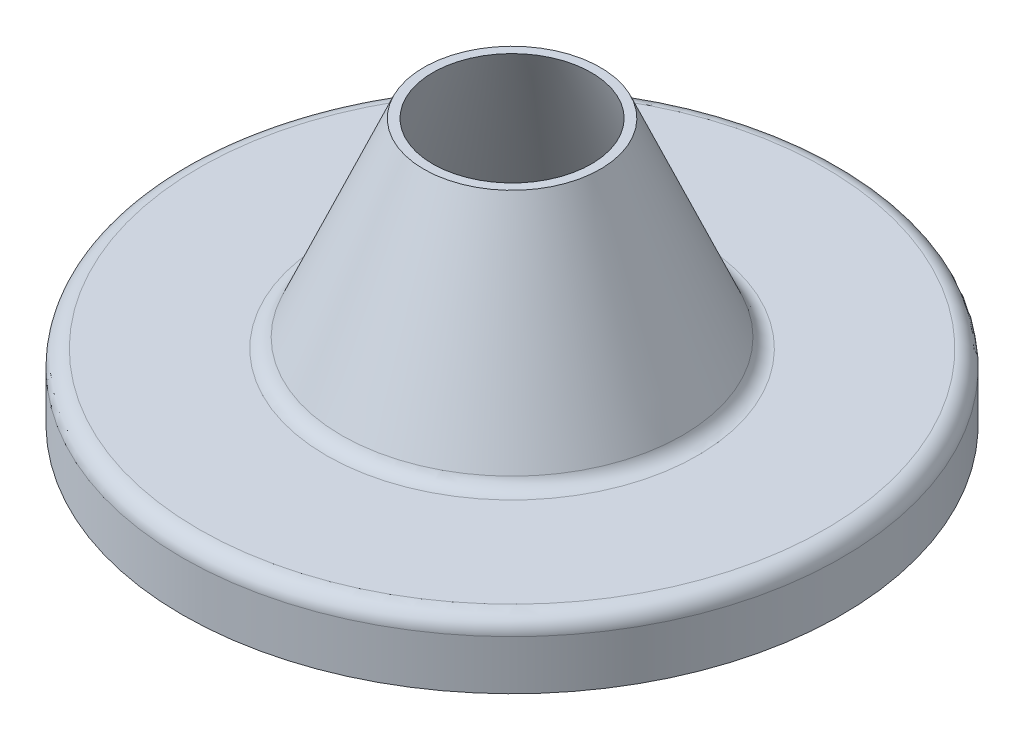
from build123d import *


with BuildPart() as part:
    # Sketch1 → Revolve1 (revolve)
    with BuildSketch(Plane.XY):
        with BuildLine():
            Line((4.875, -5.826579261), (4.875, -5.201579261))
            ThreePointArc((4.875, -5.201579261), (4.801776695, -5.024802566), (4.625, -4.951579261))
            Line((4.625, -4.951579261), (2.732064867, -4.951579261))
            ThreePointArc((2.732064867, -4.951579261), (2.5948615, -4.910565471), (2.502675973, -4.800981149))
            Line((2.502675973, -4.800981149), (1.2026756, -1.800981305))
            Line((1.2026756, -1.800981305), (1.33890713, -1.800981305))
            Line((1.33890713, -1.800981305), (2.584740818, -4.675981149))
            ThreePointArc((2.584740818, -4.675981149), (2.676926345, -4.785565471), (2.814129712, -4.826579261))
            Line((2.814129712, -4.826579261), (4.75, -4.826579261))
            ThreePointArc((4.75, -4.826579261), (4.926776695, -4.899802566), (5, -5.076579261))
            Line((5, -5.076579261), (5, -5.826579261))
            Line((5, -5.826579261), (4.875, -5.826579261))
        make_face()
    revolve(axis=Axis((0, 35.64022646, 0), (0, -1, 0)))


solid = part.part
